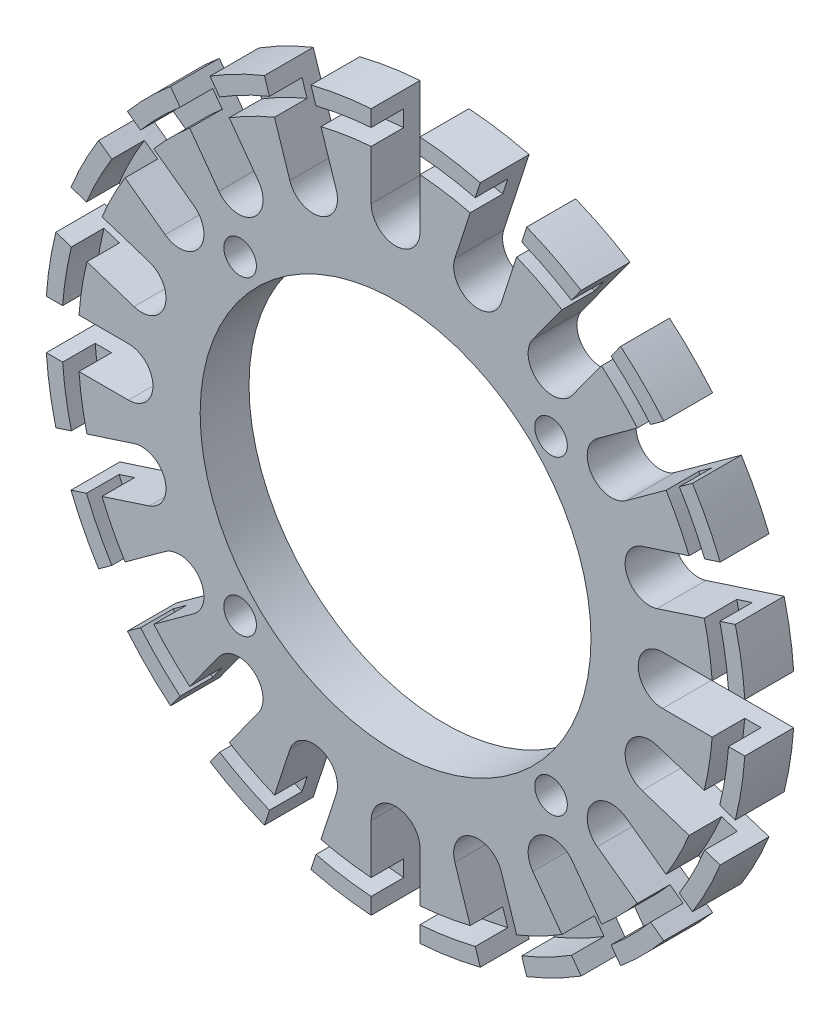
from build123d import *

# Parameters (mm, degrees)
SKETCH1_R           = 12
SKETCH1_R_2         = 1
BOSS_EXTRUDE1_DEPTH = 3
SKETCH2_R           = 20.5
SKETCH2_R_2         = 19.5
CUT_EXTRUDE1_DEPTH  = 2
SKETCH3_R           = 14.9
SKETCH3_R_2         = 12
BOSS_EXTRUDE2_DEPTH = 3
SKETCH4_R           = 1
CUT_EXTRUDE3_DEPTH  = 10


with BuildPart() as part:
    # Sketch1 → Boss-Extrude1 (new body)
    with BuildSketch(Plane.XY):
        with BuildLine():
            Line((-1.5, 16.4), (-1.5, 21.44761059))
            ThreePointArc((-1.5, 21.44761059), (-3.363340998, 21.235299323), (-5.201091386, 20.861415302))
            Line((-5.201091386, 20.861415302), (-3.641293933, 16.060852359))
            ThreePointArc((-3.641293933, 16.060852359), (-4.604353216, 14.170742093), (-6.494463482, 15.133801376))
            Line((-6.494463482, 15.133801376), (-8.054260935, 19.934364319))
            ThreePointArc((-8.054260935, 19.934364319), (-9.760795744, 19.15664027), (-11.39306371, 18.233159334))
            Line((-11.39306371, 18.233159334), (-8.426152646, 14.149556586))
            ThreePointArc((-8.426152646, 14.149556586), (-8.758000259, 12.054353216), (-10.853203629, 12.386200829))
            Line((-10.853203629, 12.386200829), (-13.820114693, 16.469803577))
            ThreePointArc((-13.820114693, 16.469803577), (-15.202795796, 15.202795796), (-16.469803577, 13.820114693))
            Line((-16.469803577, 13.820114693), (-12.386200829, 10.853203629))
            ThreePointArc((-12.386200829, 10.853203629), (-12.054353216, 8.758000259), (-14.149556586, 8.426152646))
            Line((-14.149556586, 8.426152646), (-18.233159334, 11.39306371))
            ThreePointArc((-18.233159334, 11.39306371), (-19.15664027, 9.760795744), (-19.934364319, 8.054260935))
            Line((-19.934364319, 8.054260935), (-15.133801376, 6.494463482))
            ThreePointArc((-15.133801376, 6.494463482), (-14.170742093, 4.604353216), (-16.060852359, 3.641293933))
            Line((-16.060852359, 3.641293933), (-20.861415302, 5.201091386))
            ThreePointArc((-20.861415302, 5.201091386), (-21.235299323, 3.363340998), (-21.44761059, 1.5))
            Line((-21.44761059, 1.5), (-16.4, 1.5))
            ThreePointArc((-16.4, 1.5), (-14.9, 0), (-16.4, -1.5))
            Line((-16.4, -1.5), (-21.44761059, -1.5))
            ThreePointArc((-21.44761059, -1.5), (-21.235299323, -3.363340998), (-20.861415302, -5.201091386))
            Line((-20.861415302, -5.201091386), (-16.060852359, -3.641293933))
            ThreePointArc((-16.060852359, -3.641293933), (-14.170742093, -4.604353216), (-15.133801376, -6.494463482))
            Line((-15.133801376, -6.494463482), (-19.934364319, -8.054260935))
            ThreePointArc((-19.934364319, -8.054260935), (-19.15664027, -9.760795744), (-18.233159334, -11.39306371))
            Line((-18.233159334, -11.39306371), (-14.149556586, -8.426152646))
            ThreePointArc((-14.149556586, -8.426152646), (-12.054353216, -8.758000259), (-12.386200829, -10.853203629))
            Line((-12.386200829, -10.853203629), (-16.469803577, -13.820114693))
            ThreePointArc((-16.469803577, -13.820114693), (-15.202795796, -15.202795796), (-13.820114693, -16.469803577))
            Line((-13.820114693, -16.469803577), (-10.853203629, -12.386200829))
            ThreePointArc((-10.853203629, -12.386200829), (-8.758000259, -12.054353216), (-8.426152646, -14.149556586))
            Line((-8.426152646, -14.149556586), (-11.39306371, -18.233159334))
            ThreePointArc((-11.39306371, -18.233159334), (-9.760795744, -19.15664027), (-8.054260935, -19.934364319))
            Line((-8.054260935, -19.934364319), (-6.494463482, -15.133801376))
            ThreePointArc((-6.494463482, -15.133801376), (-4.604353216, -14.170742093), (-3.641293933, -16.060852359))
            Line((-3.641293933, -16.060852359), (-5.201091386, -20.861415302))
            ThreePointArc((-5.201091386, -20.861415302), (-3.363340998, -21.235299323), (-1.5, -21.44761059))
            Line((-1.5, -21.44761059), (-1.5, -16.4))
            ThreePointArc((-1.5, -16.4), (0, -14.9), (1.5, -16.4))
            Line((1.5, -16.4), (1.5, -21.44761059))
            ThreePointArc((1.5, -21.44761059), (3.363340998, -21.235299323), (5.201091386, -20.861415302))
            Line((5.201091386, -20.861415302), (3.641293933, -16.060852359))
            ThreePointArc((3.641293933, -16.060852359), (4.604353216, -14.170742093), (6.494463482, -15.133801376))
            Line((6.494463482, -15.133801376), (8.054260935, -19.934364319))
            ThreePointArc((8.054260935, -19.934364319), (9.760795744, -19.15664027), (11.39306371, -18.233159334))
            Line((11.39306371, -18.233159334), (8.426152646, -14.149556586))
            ThreePointArc((8.426152646, -14.149556586), (8.758000259, -12.054353216), (10.853203629, -12.386200829))
            Line((10.853203629, -12.386200829), (13.820114693, -16.469803577))
            ThreePointArc((13.820114693, -16.469803577), (15.202795796, -15.202795796), (16.469803577, -13.820114693))
            Line((16.469803577, -13.820114693), (12.386200829, -10.853203629))
            ThreePointArc((12.386200829, -10.853203629), (12.054353216, -8.758000259), (14.149556586, -8.426152646))
            Line((14.149556586, -8.426152646), (18.233159334, -11.39306371))
            ThreePointArc((18.233159334, -11.39306371), (19.15664027, -9.760795744), (19.934364319, -8.054260935))
            Line((19.934364319, -8.054260935), (15.133801376, -6.494463482))
            ThreePointArc((15.133801376, -6.494463482), (14.170742093, -4.604353216), (16.060852359, -3.641293933))
            Line((16.060852359, -3.641293933), (20.861415302, -5.201091386))
            ThreePointArc((20.861415302, -5.201091386), (21.235299323, -3.363340998), (21.44761059, -1.5))
            Line((21.44761059, -1.5), (16.4, -1.5))
            ThreePointArc((16.4, -1.5), (14.9, 0), (16.4, 1.5))
            Line((16.4, 1.5), (21.44761059, 1.5))
            ThreePointArc((21.44761059, 1.5), (21.235299323, 3.363340998), (20.861415302, 5.201091386))
            Line((20.861415302, 5.201091386), (16.060852359, 3.641293933))
            ThreePointArc((16.060852359, 3.641293933), (14.170742093, 4.604353216), (15.133801376, 6.494463482))
            Line((15.133801376, 6.494463482), (19.934364319, 8.054260935))
            ThreePointArc((19.934364319, 8.054260935), (19.15664027, 9.760795744), (18.233159334, 11.39306371))
            Line((18.233159334, 11.39306371), (14.149556586, 8.426152646))
            ThreePointArc((14.149556586, 8.426152646), (12.054353216, 8.758000259), (12.386200829, 10.853203629))
            Line((12.386200829, 10.853203629), (16.469803577, 13.820114693))
            ThreePointArc((16.469803577, 13.820114693), (15.202795796, 15.202795796), (13.820114693, 16.469803577))
            Line((13.820114693, 16.469803577), (10.853203629, 12.386200829))
            ThreePointArc((10.853203629, 12.386200829), (8.758000259, 12.054353216), (8.426152646, 14.149556586))
            Line((8.426152646, 14.149556586), (11.39306371, 18.233159334))
            ThreePointArc((11.39306371, 18.233159334), (9.760795744, 19.15664027), (8.054260935, 19.934364319))
            Line((8.054260935, 19.934364319), (6.494463482, 15.133801376))
            ThreePointArc((6.494463482, 15.133801376), (4.604353216, 14.170742093), (3.641293933, 16.060852359))
            Line((3.641293933, 16.060852359), (5.201091386, 20.861415302))
            ThreePointArc((5.201091386, 20.861415302), (3.363340998, 21.235299323), (1.5, 21.44761059))
            Line((1.5, 21.44761059), (1.5, 16.4))
            ThreePointArc((1.5, 16.4), (0, 14.9), (-1.5, 16.4))
        make_face()
        Circle(SKETCH1_R, mode=Mode.SUBTRACT)
        with Locations((0, 13.5)):
            Circle(SKETCH1_R_2, mode=Mode.SUBTRACT)
        with Locations((13.5, 0)):
            Circle(SKETCH1_R_2, mode=Mode.SUBTRACT)
        with Locations((0, -13.5)):
            Circle(SKETCH1_R_2, mode=Mode.SUBTRACT)
        with Locations((-13.5, 0)):
            Circle(SKETCH1_R_2, mode=Mode.SUBTRACT)
    extrude(amount=BOSS_EXTRUDE1_DEPTH)

    # Sketch2 → Cut-Extrude1 (cut)
    with BuildSketch(Plane.XY.offset(3)):
        Circle(SKETCH2_R)
        Circle(SKETCH2_R_2, mode=Mode.SUBTRACT)
    extrude(amount=-CUT_EXTRUDE1_DEPTH, mode=Mode.SUBTRACT)

    # Sketch3 → Boss-Extrude2 (add)
    with BuildSketch(Plane.XY.offset(3)):
        Circle(SKETCH3_R)
        Circle(SKETCH3_R_2, mode=Mode.SUBTRACT)
    extrude(amount=-BOSS_EXTRUDE2_DEPTH)

    # Sketch4 → Cut-Extrude3 (cut)
    with BuildSketch(Plane.XY.offset(3)):
        with Locations((9.545941546, 9.545941546)):
            Circle(SKETCH4_R)
        with Locations((9.545941546, -9.545941546)):
            Circle(SKETCH4_R)
        with Locations((-9.545941546, -9.545941546)):
            Circle(SKETCH4_R)
        with Locations((-9.545941546, 9.545941546)):
            Circle(SKETCH4_R)
    extrude(amount=-CUT_EXTRUDE3_DEPTH, mode=Mode.SUBTRACT)


solid = part.part
